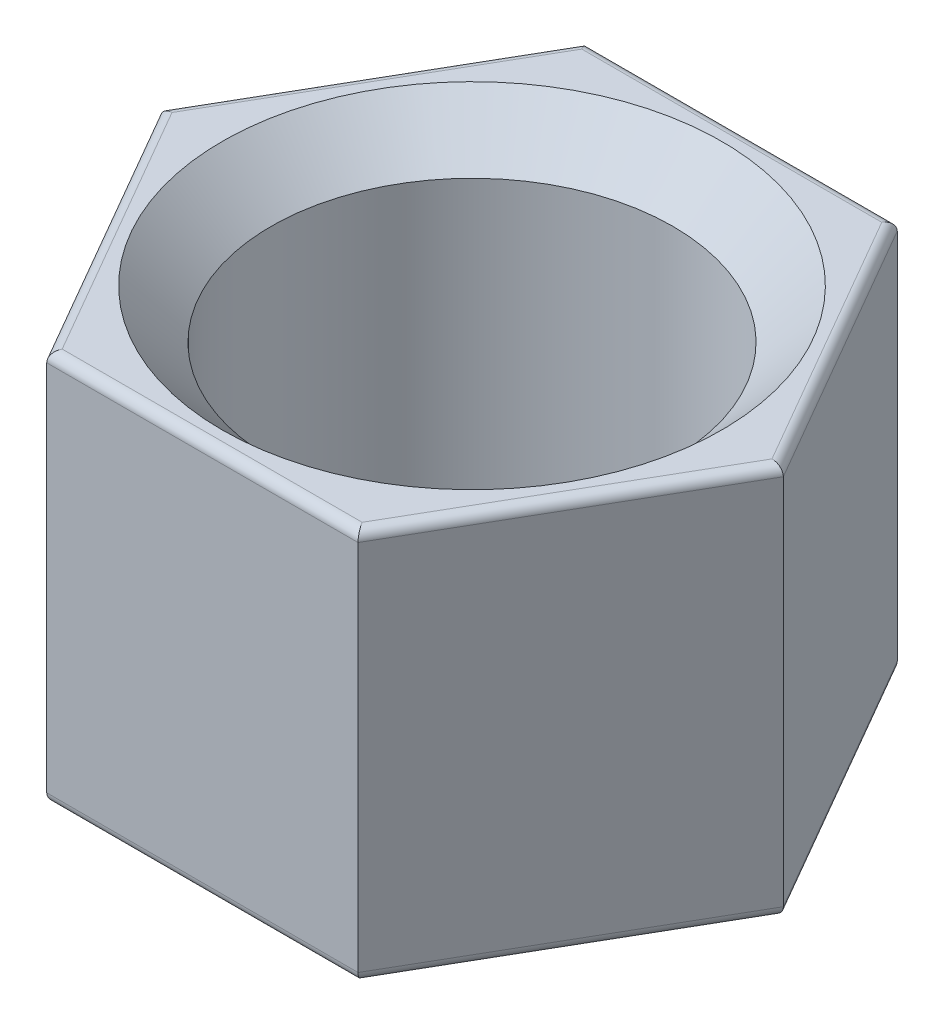
from build123d import *

# Parameters (mm, degrees)
BOSS_EXTRUDE5_DEPTH                = 2
M2_5X0_45_TAPPED_HOLE1_D           = 2.05
M2_5X0_45_TAPPED_HOLE1_CSINK_D     = 2.55
M2_5X0_45_TAPPED_HOLE1_CSINK_ANGLE = 90
FILLET1_R                          = 0.05
FILLET2_R                          = 0.05


with BuildPart() as part:
    # Sketch1 → Boss-Extrude5 (new body)
    with BuildSketch(Plane(origin=(0, 0, 0), x_dir=(1, 0, 0), z_dir=(0, 1, 0))):
        Polygon((1.588448583, 0), (0.794224291, 1.375636825), (-0.794224291, 1.375636825), (-1.588448583, 0), (-0.794224291, -1.375636825), (0.794224291, -1.375636825), align=None)
    extrude(amount=BOSS_EXTRUDE5_DEPTH)

    # M2.5x0.45 Tapped Hole1 (through all)
    with Locations(Plane(origin=(0, 2, 0), x_dir=(1, 0, 0), z_dir=(0, 1, 0))):
        with Locations((0, 0)):
            CounterSinkHole(M2_5X0_45_TAPPED_HOLE1_D / 2, M2_5X0_45_TAPPED_HOLE1_CSINK_D / 2, counter_sink_angle=M2_5X0_45_TAPPED_HOLE1_CSINK_ANGLE)

    # Fillet1
    fillet1_edges = [part.edges().sort_by_distance(p)[0] for p in [
        (0, 2, -1.375636825),
        (-1.191336437, 2, -0.687818413),
        (-1.191336437, 2, 0.687818413),
        (0, 2, 1.375636825),
        (1.191336437, 2, 0.687818413),
        (1.191336437, 2, -0.687818413),
    ]]
    fillet(fillet1_edges, radius=FILLET1_R)

    # Fillet2
    fillet2_edges = [part.edges().sort_by_distance(p)[0] for p in [
        (0, 0, 1.375636825),
        (-1.191336437, 0, 0.687818413),
        (-1.191336437, 0, -0.687818413),
        (0, 0, -1.375636825),
        (1.191336437, 0, -0.687818413),
        (1.191336437, 0, 0.687818413),
    ]]
    fillet(fillet2_edges, radius=FILLET2_R)


solid = part.part
